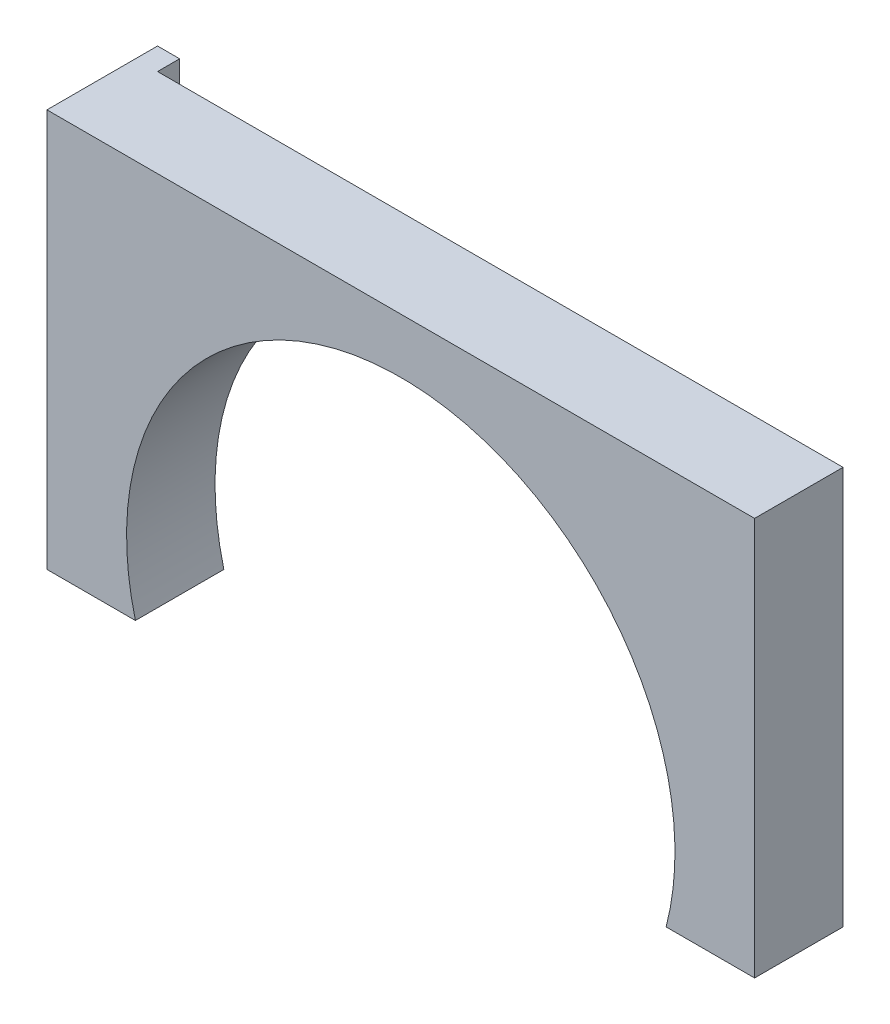
from build123d import *

# Parameters (mm, degrees)
BOSS_EXTRUDE1_DEPTH = 20
SKETCH4_W           = 5
SKETCH4_H           = 90
BOSS_EXTRUDE4_DEPTH = 5


with BuildPart() as part:
    # Sketch1 → Boss-Extrude1 (new body)
    with BuildSketch(Plane.XY):
        with BuildLine():
            Line((-80, 74.379500648), (-80, -15.620499352))
            Line((-80, -15.620499352), (-60, -15.620499352))
            ThreePointArc((-60, -15.620499352), (0, 62), (60, -15.620499352))
            Line((60, -15.620499352), (80, -15.620499352))
            Line((80, -15.620499352), (80, 74.379500648))
            Line((80, 74.379500648), (-80, 74.379500648))
        make_face()
    extrude(amount=BOSS_EXTRUDE1_DEPTH)

    # Sketch4 → Boss-Extrude4 (add)
    with BuildSketch(Plane(origin=(0, 0, 0), x_dir=(-1, 0, 0), z_dir=(0, 0, -1))):
        with Locations((77.5, 29.379500648)):
            Rectangle(SKETCH4_W, SKETCH4_H)
    extrude(amount=BOSS_EXTRUDE4_DEPTH)


solid = part.part
